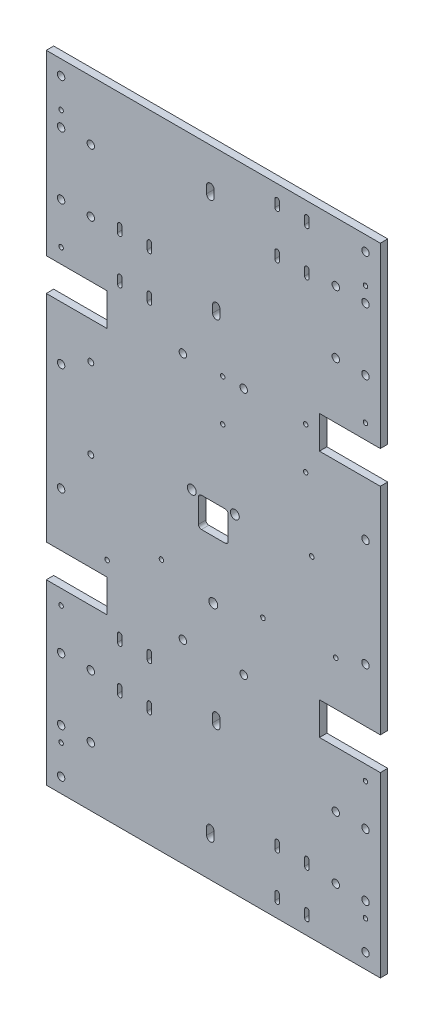
from build123d import *

# Parameters (mm, degrees)
BOSS_EXTRUDE1_DEPTH     = 5
SKETCH4_R               = 2.5
CUT_EXTRUDE2_DEPTH      = 10
MIRROR2_COPY_1_SKETCH_R = 2.5
MIRROR2_COPY_1_DEPTH    = 10
SKETCH5_R               = 2.5
SKETCH5_R_2             = 1.5
CUT_EXTRUDE3_DEPTH      = 60
SKETCH6_R               = 1.55
SKETCH6_R_2             = 1.5
SKETCH6_R_3             = 2
CUT_EXTRUDE4_DEPTH      = 10
CUT_EXTRUDE5_DEPTH      = 10
SKETCH8_W               = 250.985154516
SKETCH8_H               = 40.683624028
SKETCH8_W_2             = 269.713491433
SKETCH8_H_2             = 43.944300459
CUT_EXTRUDE6_DEPTH      = 10
SKETCH10_R              = 3
CUT_EXTRUDE7_DEPTH      = 10
SKETCH12_R              = 1.5
CUT_EXTRUDE8_DEPTH      = 10


with BuildPart() as part:
    # Sketch1 → Boss-Extrude1 (new body)
    with BuildSketch(Plane.XY):
        Polygon((-112.5, 72.5), (-112.5, -72.5), (-71.5, -72.5), (-71.5, -94.5), (-112.5, -94.5), (-112.5, -244.5), (112.5, -244.5), (112.5, -94.5), (71.5, -94.5), (71.5, -72.5), (112.5, -72.5), (112.5, 72.5), (71.5, 72.5), (71.5, 94.5), (112.5, 94.5), (112.5, 244.5), (-112.5, 244.5), (-112.5, 94.5), (-71.5, 94.5), (-71.5, 72.5), align=None)
    extrude(amount=BOSS_EXTRUDE1_DEPTH)

    # Sketch4 → Cut-Extrude2 (cut)
    with BuildSketch(Plane.XY.offset(5)):
        with Locations((-102.5, 174.31)):
            Circle(SKETCH4_R)
        with Locations((-102.5, 132.31)):
            Circle(SKETCH4_R)
        with Locations((-82.5, 174.31)):
            Circle(SKETCH4_R)
        with Locations((-82.5, 132.31)):
            Circle(SKETCH4_R)
    cut_extrude2 = extrude(amount=-CUT_EXTRUDE2_DEPTH, mode=Mode.SUBTRACT)

    # Mirror1: Cut-Extrude2 across plane
    add(cut_extrude2.mirror(Plane(origin=(0, 0, 0), x_dir=(0, 0, 1), z_dir=(1, 0, 0))), mode=Mode.SUBTRACT)

    # Mirror2: Cut-Extrude2 across plane
    add(cut_extrude2.mirror(Plane.ZX), mode=Mode.SUBTRACT)

    # Mirror2 copy 1 sketch → Mirror2 copy 1 (cut)
    with BuildSketch(Plane(origin=(0, 0, 5), x_dir=(-1, 0, 0), z_dir=(0, 0, 1))):
        with Locations((-102.5, 174.31)):
            Circle(MIRROR2_COPY_1_SKETCH_R)
        with Locations((-102.5, 132.31)):
            Circle(MIRROR2_COPY_1_SKETCH_R)
        with Locations((-82.5, 174.31)):
            Circle(MIRROR2_COPY_1_SKETCH_R)
        with Locations((-82.5, 132.31)):
            Circle(MIRROR2_COPY_1_SKETCH_R)
    extrude(amount=-MIRROR2_COPY_1_DEPTH, mode=Mode.SUBTRACT)

    # Sketch5 → Cut-Extrude3 (cut)
    with BuildSketch(Plane.XY.offset(5)):
        with Locations((-102.5, 204.31)):
            Circle(SKETCH5_R)
        with Locations((-102.5, 36.25)):
            Circle(SKETCH5_R)
        with Locations((-102.5, -36.25)):
            Circle(SKETCH5_R)
        with Locations((-102.5, -204.31)):
            Circle(SKETCH5_R)
        with Locations((102.5, -204.31)):
            Circle(SKETCH5_R)
        with Locations((102.5, 204.31)):
            Circle(SKETCH5_R)
        with Locations((102.5, 36.25)):
            Circle(SKETCH5_R)
        with Locations((-20.5, -83.5)):
            Circle(SKETCH5_R)
        with Locations((20.5, -83.5)):
            Circle(SKETCH5_R)
        with Locations((-20.5, 83.5)):
            Circle(SKETCH5_R)
        with Locations((20.5, 83.5)):
            Circle(SKETCH5_R)
        with Locations((102.5, -36.25)):
            Circle(SKETCH5_R)
        with Locations((62.201780093, 83.5)):
            Circle(SKETCH5_R_2)
        with Locations((62.201780093, 55.56)):
            Circle(SKETCH5_R_2)
        with Locations((6.321780093, 55.56)):
            Circle(SKETCH5_R_2)
        with Locations((6.321780093, 83.5)):
            Circle(SKETCH5_R_2)
    extrude(amount=-CUT_EXTRUDE3_DEPTH, mode=Mode.SUBTRACT)

    # Sketch6 → Cut-Extrude4 (cut)
    with BuildSketch(Plane.XY.offset(5)):
        with Locations((33.45, -43.7)):
            Circle(SKETCH6_R)
        with Locations((82.5, -42.5)):
            Circle(SKETCH6_R)
        with Locations((66.3, 8.5)):
            Circle(SKETCH6_R)
        with Locations((102.5, -104.5)):
            Circle(SKETCH6_R_2)
        with Locations((-102.5, -104.5)):
            Circle(SKETCH6_R_2)
        with Locations((102.5, 184.5)):
            Circle(SKETCH6_R_2)
        with Locations((-102.5, 184.5)):
            Circle(SKETCH6_R_2)
        with Locations((-102.5, 104.5)):
            Circle(SKETCH6_R_2)
        with Locations((102.5, 104.5)):
            Circle(SKETCH6_R_2)
        with Locations((-102.5, -184.5)):
            Circle(SKETCH6_R_2)
        with Locations((102.5, -184.5)):
            Circle(SKETCH6_R_2)
        with Locations((-82.5, 47.5)):
            Circle(SKETCH6_R_3)
        with Locations((-82.5, -6.5)):
            Circle(SKETCH6_R_3)
    extrude(amount=-CUT_EXTRUDE4_DEPTH, mode=Mode.SUBTRACT)

    # Sketch7 → Cut-Extrude5 (cut)
    with BuildSketch(Plane(origin=(0, 0, 0), x_dir=(1, 0, 0), z_dir=(0, 0, -1))):
        with BuildLine():
            Line((44.5, 204.62), (44.5, 199.62))
            ThreePointArc((44.5, 199.62), (43, 198.12), (41.5, 199.62))
            Line((41.5, 199.62), (41.5, 204.62))
            ThreePointArc((41.5, 204.62), (43, 206.12), (44.5, 204.62))
        make_face()
        with BuildLine():
            Line((61.5, 199.62), (61.5, 204.62))
            ThreePointArc((61.5, 204.62), (63, 206.12), (64.5, 204.62))
            Line((64.5, 204.62), (64.5, 199.62))
            ThreePointArc((64.5, 199.62), (63, 198.12), (61.5, 199.62))
        make_face()
        with BuildLine():
            Line((41.5, 169.62), (41.5, 174.62))
            ThreePointArc((41.5, 174.62), (43, 176.12), (44.5, 174.62))
            Line((44.5, 174.62), (44.5, 169.62))
            ThreePointArc((44.5, 169.62), (43, 168.12), (41.5, 169.62))
        make_face()
        with BuildLine():
            Line((61.5, 169.62), (61.5, 174.62))
            ThreePointArc((61.5, 174.62), (63, 176.12), (64.5, 174.62))
            Line((64.5, 174.62), (64.5, 169.62))
            ThreePointArc((64.5, 169.62), (63, 168.12), (61.5, 169.62))
        make_face()
        with BuildLine():
            Line((-44.5, 132), (-44.5, 137))
            ThreePointArc((-44.5, 137), (-43, 138.5), (-41.5, 137))
            Line((-41.5, 137), (-41.5, 132))
            ThreePointArc((-41.5, 132), (-43, 130.5), (-44.5, 132))
        make_face()
        with BuildLine():
            Line((-64.5, 132), (-64.5, 137))
            ThreePointArc((-64.5, 137), (-63, 138.5), (-61.5, 137))
            Line((-61.5, 137), (-61.5, 132))
            ThreePointArc((-61.5, 132), (-63, 130.5), (-64.5, 132))
        make_face()
        with BuildLine():
            Line((-44.5, 102), (-44.5, 107))
            ThreePointArc((-44.5, 107), (-43, 108.5), (-41.5, 107))
            Line((-41.5, 107), (-41.5, 102))
            ThreePointArc((-41.5, 102), (-43, 100.5), (-44.5, 102))
        make_face()
        with BuildLine():
            Line((-64.5, 102), (-64.5, 107))
            ThreePointArc((-64.5, 107), (-63, 108.5), (-61.5, 107))
            Line((-61.5, 107), (-61.5, 102))
            ThreePointArc((-61.5, 102), (-63, 100.5), (-64.5, 102))
        make_face()
        with BuildLine():
            Line((-41.5, -102), (-41.5, -107))
            ThreePointArc((-41.5, -107), (-43, -108.5), (-44.5, -107))
            Line((-44.5, -107), (-44.5, -102))
            ThreePointArc((-44.5, -102), (-43, -100.5), (-41.5, -102))
        make_face()
        with BuildLine():
            Line((-61.5, -102), (-61.5, -107))
            ThreePointArc((-61.5, -107), (-63, -108.5), (-64.5, -107))
            Line((-64.5, -107), (-64.5, -102))
            ThreePointArc((-64.5, -102), (-63, -100.5), (-61.5, -102))
        make_face()
        with BuildLine():
            Line((-44.5, -137), (-44.5, -132))
            ThreePointArc((-44.5, -132), (-43, -130.5), (-41.5, -132))
            Line((-41.5, -132), (-41.5, -137))
            ThreePointArc((-41.5, -137), (-43, -138.5), (-44.5, -137))
        make_face()
        with BuildLine():
            Line((-64.5, -137), (-64.5, -132))
            ThreePointArc((-64.5, -132), (-63, -130.5), (-61.5, -132))
            Line((-61.5, -132), (-61.5, -137))
            ThreePointArc((-61.5, -137), (-63, -138.5), (-64.5, -137))
        make_face()
        with BuildLine():
            Line((61.5, -174.62), (61.5, -169.62))
            ThreePointArc((61.5, -169.62), (63, -168.12), (64.5, -169.62))
            Line((64.5, -169.62), (64.5, -174.62))
            ThreePointArc((64.5, -174.62), (63, -176.12), (61.5, -174.62))
        make_face()
        with BuildLine():
            Line((41.5, -174.62), (41.5, -169.62))
            ThreePointArc((41.5, -169.62), (43, -168.12), (44.5, -169.62))
            Line((44.5, -169.62), (44.5, -174.62))
            ThreePointArc((44.5, -174.62), (43, -176.12), (41.5, -174.62))
        make_face()
        with BuildLine():
            Line((61.5, -204.62), (61.5, -199.62))
            ThreePointArc((61.5, -199.62), (63, -198.12), (64.5, -199.62))
            Line((64.5, -199.62), (64.5, -204.62))
            ThreePointArc((64.5, -204.62), (63, -206.12), (61.5, -204.62))
        make_face()
        with BuildLine():
            Line((41.5, -204.62), (41.5, -199.62))
            ThreePointArc((41.5, -199.62), (43, -198.12), (44.5, -199.62))
            Line((44.5, -199.62), (44.5, -204.62))
            ThreePointArc((44.5, -204.62), (43, -206.12), (41.5, -204.62))
        make_face()
        with BuildLine():
            Line((4.5, -117), (4.5, -122))
            ThreePointArc((4.5, -122), (2, -124.5), (-0.5, -122))
            Line((-0.5, -122), (-0.5, -117))
            ThreePointArc((-0.5, -117), (2, -114.5), (4.5, -117))
        make_face()
        with BuildLine():
            Line((0.5, -184.62), (0.5, -189.62))
            ThreePointArc((0.5, -189.62), (-2, -192.12), (-4.5, -189.62))
            Line((-4.5, -189.62), (-4.5, -184.62))
            ThreePointArc((-4.5, -184.62), (-2, -182.12), (0.5, -184.62))
        make_face()
        with BuildLine():
            Line((4.5, 122), (4.5, 117))
            ThreePointArc((4.5, 117), (2, 114.5), (-0.5, 117))
            Line((-0.5, 117), (-0.5, 122))
            ThreePointArc((-0.5, 122), (2, 124.5), (4.5, 122))
        make_face()
        with BuildLine():
            Line((0.5, 189.62), (0.5, 184.62))
            ThreePointArc((0.5, 184.62), (-2, 182.12), (-4.5, 184.62))
            Line((-4.5, 184.62), (-4.5, 189.62))
            ThreePointArc((-4.5, 189.62), (-2, 192.12), (0.5, 189.62))
        make_face()
    extrude(amount=-CUT_EXTRUDE5_DEPTH, mode=Mode.SUBTRACT)

    # Sketch8 → Cut-Extrude6 (cut)
    with BuildSketch(Plane.XY.offset(5)):
        with Locations((-0.320406555, -234.651812014)):
            Rectangle(SKETCH8_W, SKETCH8_H)
        with Locations((3.360826593, 236.28215023)):
            Rectangle(SKETCH8_W_2, SKETCH8_H_2)
    extrude(amount=-CUT_EXTRUDE6_DEPTH, mode=Mode.SUBTRACT)

    # Sketch10 → Cut-Extrude7 (cut)
    with BuildSketch(Plane(origin=(0, 0, 0), x_dir=(-1, 0, 0), z_dir=(0, 0, -1))):
        with Locations((0, -51.943)):
            Circle(SKETCH10_R)
        with Locations((-14.5, 7.057)):
            Circle(SKETCH10_R)
        with Locations((14.5, 7.057)):
            Circle(SKETCH10_R)
        with BuildLine():
            Line((-8, 7.057), (8, 7.057))
            ThreePointArc((8, 7.057), (9.414213562, 6.471213562), (10, 5.057))
            Line((10, 5.057), (10, -10.943))
            ThreePointArc((10, -10.943), (9.414213562, -12.357213562), (8, -12.943))
            Line((8, -12.943), (-8, -12.943))
            ThreePointArc((-8, -12.943), (-9.414213562, -12.357213562), (-10, -10.943))
            Line((-10, -10.943), (-10, 5.057))
            ThreePointArc((-10, 5.057), (-9.414213562, 6.471213562), (-8, 7.057))
        make_face()
    extrude(amount=-CUT_EXTRUDE7_DEPTH, mode=Mode.SUBTRACT)

    # Sketch12 → Cut-Extrude8 (cut)
    with BuildSketch(Plane(origin=(0, 0, 0), x_dir=(-1, 0, 0), z_dir=(0, 0, -1))):
        with Locations((71.5, -62.5)):
            Circle(SKETCH12_R)
        with Locations((34.924, -43.958)):
            Circle(SKETCH12_R)
    extrude(amount=-CUT_EXTRUDE8_DEPTH, mode=Mode.SUBTRACT)


solid = part.part
